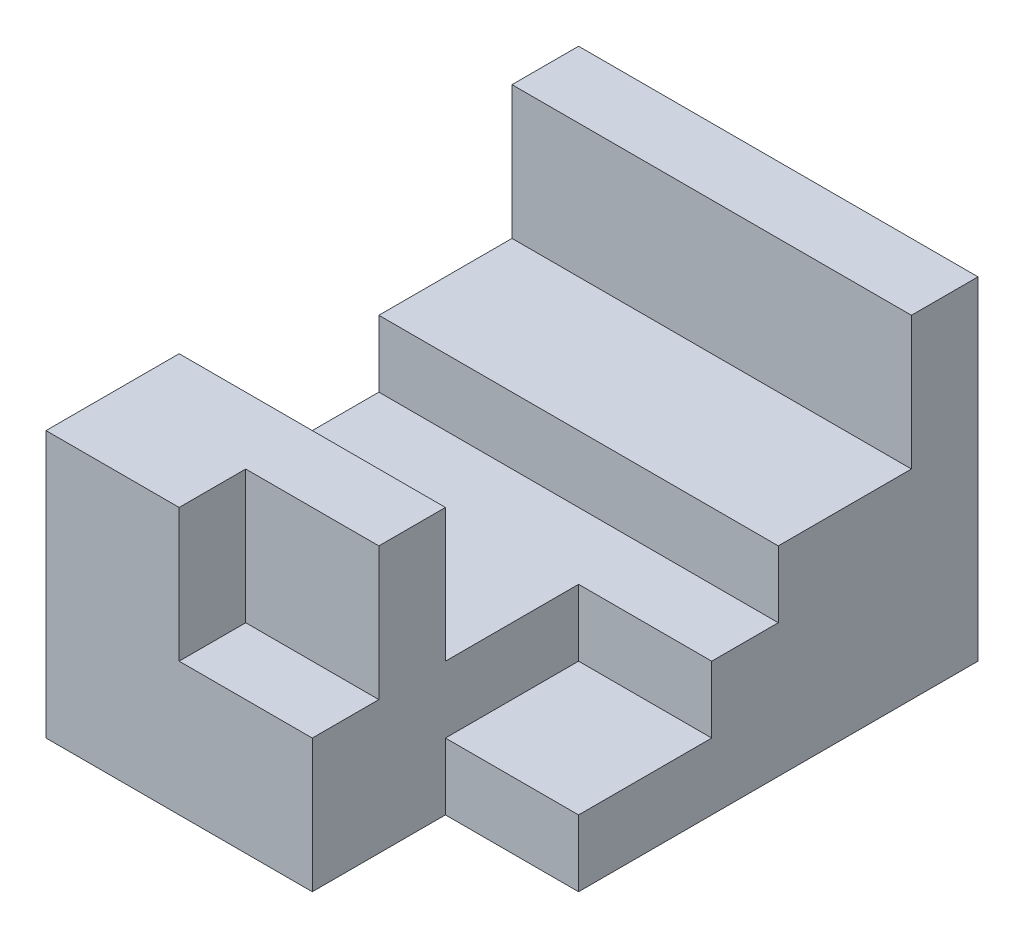
from build123d import *

# Parameters (mm, degrees)
SKETCH1_W           = 6
SKETCH1_H           = 5
BOSS_EXTRUDE1_DEPTH = 8
SKETCH3_W           = 2
SKETCH3_H           = 5
CUT_EXTRUDE1_DEPTH  = 2
SKETCH4_W           = 2
SKETCH4_H           = 2
CUT_EXTRUDE2_DEPTH  = 1
SKETCH5_W           = 6
SKETCH5_H           = 5
CUT_EXTRUDE3_DEPTH  = 2
SKETCH6_W           = 2
SKETCH6_H           = 2
CUT_EXTRUDE4_DEPTH  = 2
CUT_EXTRUDE5_DEPTH  = 1
SKETCH8_W           = 8.535402973
SKETCH8_H           = 3.487061374
CUT_EXTRUDE6_DEPTH  = 1
SKETCH9_W           = 2
SKETCH9_H           = 1
CUT_EXTRUDE7_DEPTH  = 1


with BuildPart() as part:
    # Sketch1 → Boss-Extrude1 (new body)
    with BuildSketch(Plane.XY):
        Rectangle(SKETCH1_W, SKETCH1_H)
    extrude(amount=BOSS_EXTRUDE1_DEPTH)

    # Sketch3 → Cut-Extrude1 (cut)
    with BuildSketch(Plane.XY.offset(8)):
        with Locations((2, 0)):
            Rectangle(SKETCH3_W, SKETCH3_H)
    extrude(amount=-CUT_EXTRUDE1_DEPTH, mode=Mode.SUBTRACT)

    # Sketch4 → Cut-Extrude2 (cut)
    with BuildSketch(Plane.XY.offset(8)):
        with Locations((0, 1.5)):
            Rectangle(SKETCH4_W, SKETCH4_H)
    extrude(amount=-CUT_EXTRUDE2_DEPTH, mode=Mode.SUBTRACT)

    # Sketch5 → Cut-Extrude3 (cut)
    with BuildSketch(Plane(origin=(0, 2.5, 0), x_dir=(1, 0, 0), z_dir=(0, 1, 0))):
        with Locations((0, -3.5)):
            Rectangle(SKETCH5_W, SKETCH5_H)
    extrude(amount=-CUT_EXTRUDE3_DEPTH, mode=Mode.SUBTRACT)

    # Sketch6 → Cut-Extrude4 (cut)
    with BuildSketch(Plane(origin=(0, 0.5, 0), x_dir=(1, 0, 0), z_dir=(0, 1, 0))):
        with Locations((2, -5)):
            Rectangle(SKETCH6_W, SKETCH6_H)
    extrude(amount=-CUT_EXTRUDE4_DEPTH, mode=Mode.SUBTRACT)

    # Sketch7 → Cut-Extrude5 (cut)
    with BuildSketch(Plane(origin=(0, 0.5, 0), x_dir=(1, 0, 0), z_dir=(0, 1, 0))):
        Polygon((3, -4), (3, -3), (-3, -3), (-3, -6), (1, -6), (1, -4), align=None)
    extrude(amount=-CUT_EXTRUDE5_DEPTH, mode=Mode.SUBTRACT)

    # Sketch8 → Cut-Extrude6 (cut)
    with BuildSketch(Plane(origin=(0, 2.5, 0), x_dir=(1, 0, 0), z_dir=(0, 1, 0))):
        with Locations((-0.885821847, -7.448525998)):
            Rectangle(SKETCH8_W, SKETCH8_H)
    extrude(amount=-CUT_EXTRUDE6_DEPTH, mode=Mode.SUBTRACT)

    # Sketch9 → Cut-Extrude7 (cut)
    with BuildSketch(Plane(origin=(0, 0.5, 0), x_dir=(1, 0, 0), z_dir=(0, 1, 0))):
        with Locations((0, -7.5)):
            Rectangle(SKETCH9_W, SKETCH9_H)
    extrude(amount=-CUT_EXTRUDE7_DEPTH, mode=Mode.SUBTRACT)


solid = part.part
